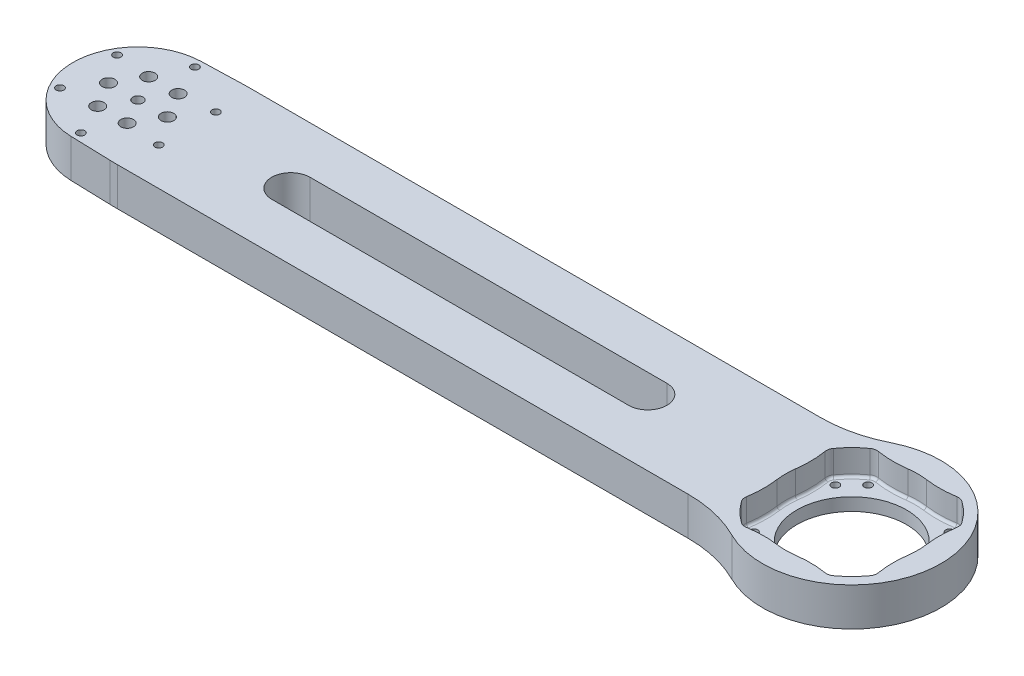
from build123d import *

# Parameters (mm, degrees)
SKETCH_1_R          = 1.5
SKETCH_1_R_2        = 21.5
SKETCH_1_R_3        = 2
EXTRUDE_1_DEPTH     = 15
SKETCH_3_R          = 2.5
SKETCH_3_R_2        = 1.5
CUT_EXTRUDE_1_DEPTH = 16
CUT_EXTRUDE_2_DEPTH = 10
FILLET_1_R          = 1
SKETCH_5_R          = 1.5
SKETCH_5_R_2        = 2.5
SKETCH_5_R_3        = 2
SKETCH_5_R_4        = 32.035606478
EXTRUDE_2_DEPTH     = 15


with BuildPart() as part:
    # 草图1 → 凸台-拉伸1 (new body)
    with BuildSketch(Plane(origin=(0, 0, 0), x_dir=(1, 0, 0), z_dir=(0, 1, 0))):
        with BuildLine():
            Line((21.685248442, 20), (239.195588474, 20))
            ThreePointArc((239.195588474, 20), (248.856506305, 21.719462207), (257.330882485, 26.666666667))
            ThreePointArc((257.330882485, 26.666666667), (315, 0), (257.330882485, -26.666666667))
            ThreePointArc((257.330882485, -26.666666667), (248.856506305, -21.719462207), (239.195588474, -20))
            Line((239.195588474, -20), (21.685248442, -20))
            ThreePointArc((21.685248442, -20), (16.768356723, -20.61381482), (12.153271105, -22.417582418))
            ThreePointArc((12.153271105, -22.417582418), (-25.5, 0), (12.153271105, 22.417582418))
            ThreePointArc((12.153271105, 22.417582418), (16.768356723, 20.61381482), (21.685248442, 20))
        make_face()
        with Locations((302.388176755, -15.969331282)):
            Circle(SKETCH_1_R, mode=Mode.SUBTRACT)
        with Locations((264.030668718, 22.388176755)):
            Circle(SKETCH_1_R, mode=Mode.SUBTRACT)
        with Locations((302.388176755, 15.969331282)):
            Circle(SKETCH_1_R, mode=Mode.SUBTRACT)
        with Locations((264.030668718, -22.388176755)):
            Circle(SKETCH_1_R, mode=Mode.SUBTRACT)
        with Locations((295.969331282, -22.388176755)):
            Circle(SKETCH_1_R, mode=Mode.SUBTRACT)
        with Locations((257.611823245, 15.969331282)):
            Circle(SKETCH_1_R, mode=Mode.SUBTRACT)
        with Locations((257.611823245, -15.969331282)):
            Circle(SKETCH_1_R, mode=Mode.SUBTRACT)
        with Locations((295.969331282, 22.388176755)):
            Circle(SKETCH_1_R, mode=Mode.SUBTRACT)
        with Locations((280, 0)):
            Circle(SKETCH_1_R_2, mode=Mode.SUBTRACT)
        Circle(SKETCH_1_R_3, mode=Mode.SUBTRACT)
        with BuildLine():
            Line((60, 7.5), (200, 7.5))
            ThreePointArc((200, 7.5), (207.5, 0), (200, -7.5))
            Line((200, -7.5), (60, -7.5))
            ThreePointArc((60, -7.5), (52.5, 0), (60, 7.5))
        make_face(mode=Mode.SUBTRACT)
    extrude(amount=EXTRUDE_1_DEPTH)

    # 草图3 → 切除-拉伸1 (cut, through all)
    with BuildSketch(Plane(origin=(0, 15, 0), x_dir=(1, 0, 0), z_dir=(0, 1, 0))):
        with Locations((-5.773502692, -10)):
            Circle(SKETCH_3_R)
        with Locations((-11.547005384, 0)):
            Circle(SKETCH_3_R)
        with Locations((-5.773502692, 10)):
            Circle(SKETCH_3_R)
        with Locations((5.773502692, 10)):
            Circle(SKETCH_3_R)
        with Locations((11.547005384, 0)):
            Circle(SKETCH_3_R)
        with Locations((5.773502692, -10)):
            Circle(SKETCH_3_R)
        with Locations((0, -22.375)):
            Circle(SKETCH_3_R_2)
        with Locations((-19.37731841, -11.1875)):
            Circle(SKETCH_3_R_2)
        with Locations((-19.37731841, 11.1875)):
            Circle(SKETCH_3_R_2)
        with Locations((0, 22.375)):
            Circle(SKETCH_3_R_2)
        with Locations((19.37731841, 11.1875)):
            Circle(SKETCH_3_R_2)
        with Locations((19.37731841, -11.1875)):
            Circle(SKETCH_3_R_2)
    extrude(amount=-CUT_EXTRUDE_1_DEPTH, mode=Mode.SUBTRACT)

    # 草图4 → 切除-拉伸2 (cut)
    with BuildSketch(Plane(origin=(0, 15, 0), x_dir=(1, 0, 0), z_dir=(0, 1, 0))):
        with BuildLine():
            ThreePointArc((283.609642241, 25.697723302), (289.509391905, 25.321470086), (295.398230667, 25.841268715))
            ThreePointArc((295.398230667, 25.841268715), (295.682819381, 25.876430033), (295.969331282, 25.888176755))
            ThreePointArc((295.969331282, 25.888176755), (297.036356329, 25.721562054), (298.001791627, 25.237581069))
            ThreePointArc((298.001791627, 25.237581069), (301.920310217, 21.920310217), (305.237581069, 18.001791627))
            ThreePointArc((305.237581069, 18.001791627), (305.797721775, 16.759902442), (305.841268715, 15.398230667))
            ThreePointArc((305.841268715, 15.398230667), (305.321470086, 9.509391905), (305.697723302, 3.609642241))
            ThreePointArc((305.697723302, 3.609642241), (305.95, 0), (305.697723302, -3.609642241))
            ThreePointArc((305.697723302, -3.609642241), (305.321470086, -9.509391905), (305.841268715, -15.398230667))
            ThreePointArc((305.841268715, -15.398230667), (305.797721775, -16.759902442), (305.237581069, -18.001791627))
            ThreePointArc((305.237581069, -18.001791627), (301.920310217, -21.920310217), (298.001791627, -25.237581069))
            ThreePointArc((298.001791627, -25.237581069), (296.759902442, -25.797721775), (295.398230667, -25.841268715))
            ThreePointArc((295.398230667, -25.841268715), (292.227099274, -25.449471177), (289.034538094, -25.318579131))
            ThreePointArc((289.034538094, -25.318579131), (286.315473672, -25.413480639), (283.609642241, -25.697723302))
            ThreePointArc((283.609642241, -25.697723302), (280, -25.95), (276.390357759, -25.697723302))
            ThreePointArc((276.390357759, -25.697723302), (273.684526328, -25.413480639), (270.965461906, -25.318579131))
            ThreePointArc((270.965461906, -25.318579131), (267.772900726, -25.449471177), (264.601769333, -25.841268715))
            ThreePointArc((264.601769333, -25.841268715), (263.240097558, -25.797721775), (261.998208373, -25.237581069))
            ThreePointArc((261.998208373, -25.237581069), (258.079689783, -21.920310217), (254.762418931, -18.001791627))
            ThreePointArc((254.762418931, -18.001791627), (254.202278225, -16.759902442), (254.158731285, -15.398230667))
            ThreePointArc((254.158731285, -15.398230667), (254.678529914, -9.509391905), (254.302276698, -3.609642241))
            ThreePointArc((254.302276698, -3.609642241), (254.05, 0), (254.302276698, 3.609642241))
            ThreePointArc((254.302276698, 3.609642241), (254.678529914, 9.509391905), (254.158731285, 15.398230667))
            ThreePointArc((254.158731285, 15.398230667), (254.202278225, 16.759902442), (254.762418931, 18.001791627))
            ThreePointArc((254.762418931, 18.001791627), (258.079689783, 21.920310217), (261.998208373, 25.237581069))
            ThreePointArc((261.998208373, 25.237581069), (262.963643671, 25.721562054), (264.030668718, 25.888176755))
            ThreePointArc((264.030668718, 25.888176755), (264.317180619, 25.876430033), (264.601769333, 25.841268715))
            ThreePointArc((264.601769333, 25.841268715), (270.490608095, 25.321470086), (276.390357759, 25.697723302))
            ThreePointArc((276.390357759, 25.697723302), (278.190776366, 25.886853997), (280, 25.95))
            ThreePointArc((280, 25.95), (281.809223634, 25.886853997), (283.609642241, 25.697723302))
        make_face()
    extrude(amount=-CUT_EXTRUDE_2_DEPTH, mode=Mode.SUBTRACT)

    # 圆角1
    fillet_1_edges = [part.edges().sort_by_distance(p)[0] for p in [
        (289.509391905, 5, -25.321470086),
        (296.759902442, 5, -25.797721775),
        (301.920310217, 5, -21.920310217),
        (305.797721775, 5, -16.759902442),
        (305.321470086, 5, -9.509391905),
        (305.95, 5, 0),
        (305.321470086, 5, 9.509391905),
        (305.797721775, 5, 16.759902442),
        (301.920310217, 5, 21.920310217),
        (296.759902442, 5, 25.797721775),
        (289.509391905, 5, 25.321470086),
        (280, 5, 25.95),
        (270.490608095, 5, 25.321470086),
        (263.240097558, 5, 25.797721775),
        (258.079689783, 5, 21.920310217),
        (254.202278225, 5, 16.759902442),
        (254.678529914, 5, 9.509391905),
        (254.05, 5, 0),
        (254.678529914, 5, -9.509391905),
        (254.202278225, 5, -16.759902442),
        (258.079689783, 5, -21.920310217),
        (263.240097558, 5, -25.797721775),
        (270.490608095, 5, -25.321470086),
        (280, 5, -25.95),
    ]]
    fillet(fillet_1_edges, radius=FILLET_1_R)

    # 草图5 → 凸台-拉伸2 (add)
    with BuildSketch(Plane(origin=(0, 15, 0), x_dir=(1, 0, 0), z_dir=(0, 1, 0))):
        with BuildLine():
            Line((-0.75510627, -25.488817441), (15.019724187, -25.956146826))
            ThreePointArc((15.019724187, -25.956146826), (16.500162367, -25.989036105), (17.980925246, -26))
            Line((17.980925246, -26), (241.854825088, -26))
            ThreePointArc((241.854825088, -26), (253.379621277, -27.346335464), (264.283767793, -31.312837088))
            ThreePointArc((264.283767793, -31.312837088), (315.035606478, 0), (264.283767793, 31.312837088))
            ThreePointArc((264.283767793, 31.312837088), (253.379621277, 27.346335464), (241.854825088, 26))
            Line((241.854825088, 26), (17.980925246, 26))
            ThreePointArc((17.980925246, 26), (16.500162367, 25.989036105), (15.019724187, 25.956146826))
            Line((15.019724187, 25.956146826), (-0.75510627, 25.488817441))
            ThreePointArc((-0.75510627, 25.488817441), (-25.5, 0), (-0.75510627, -25.488817441))
        make_face()
        with Locations((0, -22.375)):
            Circle(SKETCH_5_R, mode=Mode.SUBTRACT)
        with Locations((-19.37731841, -11.1875)):
            Circle(SKETCH_5_R, mode=Mode.SUBTRACT)
        with Locations((-5.773502692, -10)):
            Circle(SKETCH_5_R_2, mode=Mode.SUBTRACT)
        with Locations((19.37731841, -11.1875)):
            Circle(SKETCH_5_R, mode=Mode.SUBTRACT)
        with Locations((5.773502692, -10)):
            Circle(SKETCH_5_R_2, mode=Mode.SUBTRACT)
        with Locations((11.547005384, 0)):
            Circle(SKETCH_5_R_2, mode=Mode.SUBTRACT)
        Circle(SKETCH_5_R_3, mode=Mode.SUBTRACT)
        with Locations((-11.547005384, 0)):
            Circle(SKETCH_5_R_2, mode=Mode.SUBTRACT)
        with Locations((-19.37731841, 11.1875)):
            Circle(SKETCH_5_R, mode=Mode.SUBTRACT)
        with Locations((-5.773502692, 10)):
            Circle(SKETCH_5_R_2, mode=Mode.SUBTRACT)
        with Locations((5.773502692, 10)):
            Circle(SKETCH_5_R_2, mode=Mode.SUBTRACT)
        with Locations((19.37731841, 11.1875)):
            Circle(SKETCH_5_R, mode=Mode.SUBTRACT)
        with Locations((0, 22.375)):
            Circle(SKETCH_5_R, mode=Mode.SUBTRACT)
        with Locations((280, 0)):
            Circle(SKETCH_5_R_4, mode=Mode.SUBTRACT)
        with BuildLine():
            Line((60, -7.5), (200, -7.5))
            ThreePointArc((200, -7.5), (207.5, 0), (200, 7.5))
            Line((200, 7.5), (60, 7.5))
            ThreePointArc((60, 7.5), (52.5, 0), (60, -7.5))
        make_face(mode=Mode.SUBTRACT)
    extrude(amount=-EXTRUDE_2_DEPTH)


solid = part.part
